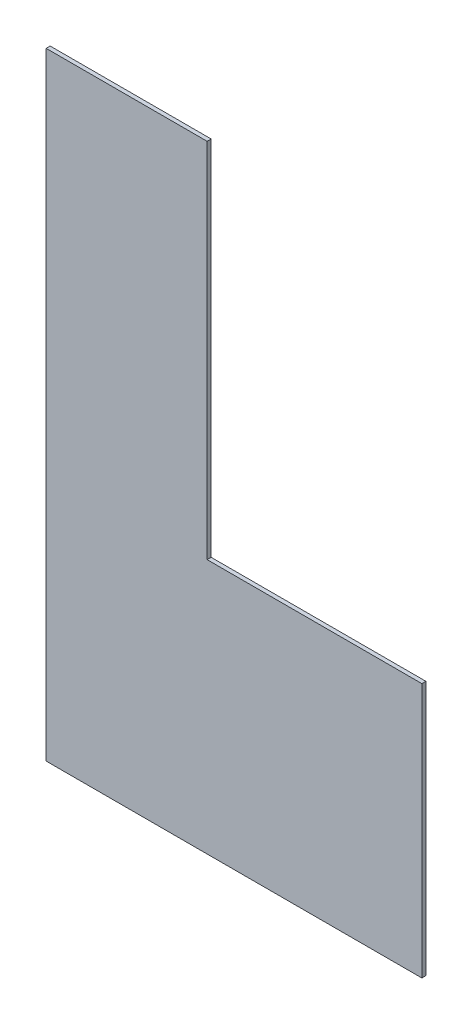
from build123d import *

# Parameters (mm, degrees)
BOSS_EXTRU_1_DEPTH = 3


with BuildPart() as part:
    # Esquisse1 → Boss.-Extru.1 (new body)
    with BuildSketch(Plane.XY):
        Polygon((-158.414514075, -408.671464143), (121.585485925, -408.671464143), (121.585485925, -218.671464143), (-38.414514075, -218.671464143), (-38.414514075, 51.328535857), (-158.414514075, 51.328535857), align=None)
    extrude(amount=BOSS_EXTRU_1_DEPTH)


solid = part.part
